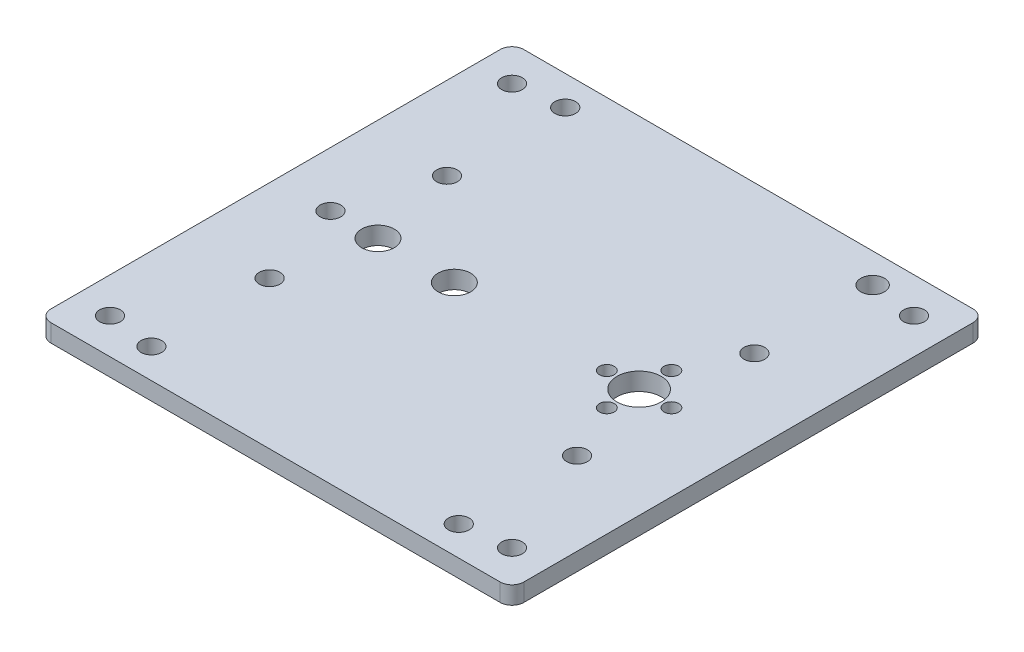
from build123d import *

# Parameters (mm, degrees)
SKETCH1_W           = 80
SKETCH1_H           = 80
BOSS_EXTRUDE1_DEPTH = 3
SKETCH2_R           = 1.75
SKETCH2_R_2         = 2.75
CUT_EXTRUDE1_DEPTH  = 4
SKETCH3_R           = 3.75
CUT_EXTRUDE2_DEPTH  = 4
SKETCH4_R           = 1.25
CUT_EXTRUDE3_DEPTH  = 4
SKETCH5_R           = 2.75
CUT_EXTRUDE4_DEPTH  = 4
SKETCH6_R           = 1.75
CUT_EXTRUDE5_DEPTH  = 4
FILLET1_R           = 2
SKETCH7_R           = 1.75
SKETCH7_R_2         = 2
CUT_EXTRUDE6_DEPTH  = 4


with BuildPart() as part:
    # Sketch1 → Boss-Extrude1 (new body)
    with BuildSketch(Plane(origin=(0, 0, 0), x_dir=(1, 0, 0), z_dir=(0, 1, 0))):
        with Locations((40, 40)):
            Rectangle(SKETCH1_W, SKETCH1_H)
    extrude(amount=BOSS_EXTRUDE1_DEPTH)

    # Sketch2 → Cut-Extrude1 (cut, through all)
    with BuildSketch(Plane(origin=(0, 3, 0), x_dir=(1, 0, 0), z_dir=(0, 1, 0))):
        with Locations((9.29, 40)):
            Circle(SKETCH2_R)
        with Locations((17.33, 40)):
            Circle(SKETCH2_R_2)
    extrude(amount=-CUT_EXTRUDE1_DEPTH, mode=Mode.SUBTRACT)

    # Sketch3 → Cut-Extrude2 (cut, through all)
    with BuildSketch(Plane(origin=(0, 3, 0), x_dir=(1, 0, 0), z_dir=(0, 1, 0))):
        with Locations((61.5, 40)):
            Circle(SKETCH3_R)
    extrude(amount=-CUT_EXTRUDE2_DEPTH, mode=Mode.SUBTRACT)

    # Sketch4 → Cut-Extrude3 (cut, through all)
    with BuildSketch(Plane(origin=(0, 3, 0), x_dir=(1, 0, 0), z_dir=(0, 1, 0))):
        with Locations((66.96, 40)):
            Circle(SKETCH4_R)
        with Locations((56.04, 40)):
            Circle(SKETCH4_R)
        with Locations((61.5, 34.54)):
            Circle(SKETCH4_R)
        with Locations((61.5, 45.46)):
            Circle(SKETCH4_R)
    extrude(amount=-CUT_EXTRUDE3_DEPTH, mode=Mode.SUBTRACT)

    # Sketch5 → Cut-Extrude4 (cut, through all)
    with BuildSketch(Plane(origin=(0, 3, 0), x_dir=(1, 0, 0), z_dir=(0, 1, 0))):
        with Locations((30.25, 40)):
            Circle(SKETCH5_R)
    extrude(amount=-CUT_EXTRUDE4_DEPTH, mode=Mode.SUBTRACT)

    # Sketch6 → Cut-Extrude5 (cut, through all)
    with BuildSketch(Plane(origin=(0, 3, 0), x_dir=(1, 0, 0), z_dir=(0, 1, 0))):
        with Locations((6, 74)):
            Circle(SKETCH6_R)
        with Locations((74, 74)):
            Circle(SKETCH6_R)
        with Locations((74, 6)):
            Circle(SKETCH6_R)
        with Locations((6, 6)):
            Circle(SKETCH6_R)
    extrude(amount=-CUT_EXTRUDE5_DEPTH, mode=Mode.SUBTRACT)

    # Fillet1
    fillet1_edges = [part.edges().sort_by_distance(p)[0] for p in [
        (0, 1.5, -80),
        (80, 1.5, -80),
        (80, 1.5, 0),
        (0, 1.5, 0),
    ]]
    fillet(fillet1_edges, radius=FILLET1_R)

    # Sketch7 → Cut-Extrude6 (cut, through all)
    with BuildSketch(Plane(origin=(0, 3, 0), x_dir=(1, 0, 0), z_dir=(0, 1, 0))):
        with Locations((14, 5)):
            Circle(SKETCH7_R)
        with Locations((66, 5)):
            Circle(SKETCH7_R)
        with Locations((66, 25)):
            Circle(SKETCH7_R)
        with Locations((14, 25)):
            Circle(SKETCH7_R)
        with Locations((14, 75)):
            Circle(SKETCH7_R)
        with Locations((14, 55)):
            Circle(SKETCH7_R)
        with Locations((66, 75)):
            Circle(SKETCH7_R_2)
        with Locations((66, 55)):
            Circle(SKETCH7_R)
    extrude(amount=-CUT_EXTRUDE6_DEPTH, mode=Mode.SUBTRACT)


solid = part.part
